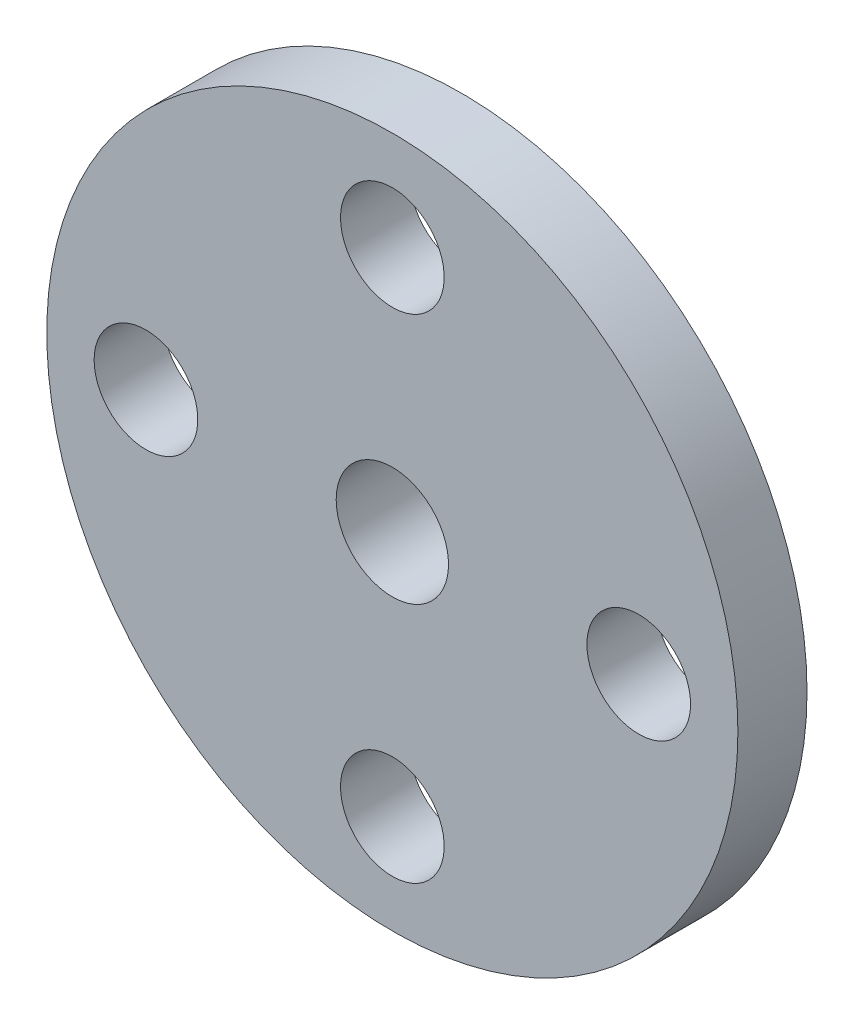
from build123d import *

# Parameters (mm, degrees)
SCHIZZO14_R                  = 10
ESTRUSIONE_ESTRUSIONE2_DEPTH = 2
FORO_3_0_3_1_D               = 3
SCHIZZO19_R                  = 4.5
ESTRUSIONE_ESTRUSIONE3_DEPTH = 2
SCHIZZO20_R                  = 1.625
TAGLIO_ESTRUSIONE1_DEPTH     = 5


with BuildPart() as part:
    # Schizzo14 → Estrusione-Estrusione2 (new body)
    with BuildSketch(Plane.XY):
        Circle(SCHIZZO14_R)
    extrude(amount=ESTRUSIONE_ESTRUSIONE2_DEPTH)

    # Foro Ø3.0 (3)-1 (through all)
    with Locations(Plane(origin=(7.13, 0, 0), x_dir=(-1, 0, 0), z_dir=(0, 0, -1))):
        with Locations((0, 0), (14.26, 0), (7.13, -7.13), (7.13, 7.13)):
            Hole(FORO_3_0_3_1_D / 2)

    # Schizzo19 → Estrusione-Estrusione3 (add)
    with BuildSketch(Plane.XY):
        Circle(SCHIZZO19_R)
    extrude(amount=-ESTRUSIONE_ESTRUSIONE3_DEPTH)

    # Schizzo20 → Taglio-Estrusione1 (cut, through all)
    with BuildSketch(Plane(origin=(0, 0, -2), x_dir=(-1, 0, 0), z_dir=(0, 0, -1))):
        Circle(SCHIZZO20_R)
    extrude(amount=-TAGLIO_ESTRUSIONE1_DEPTH, mode=Mode.SUBTRACT)


solid = part.part
